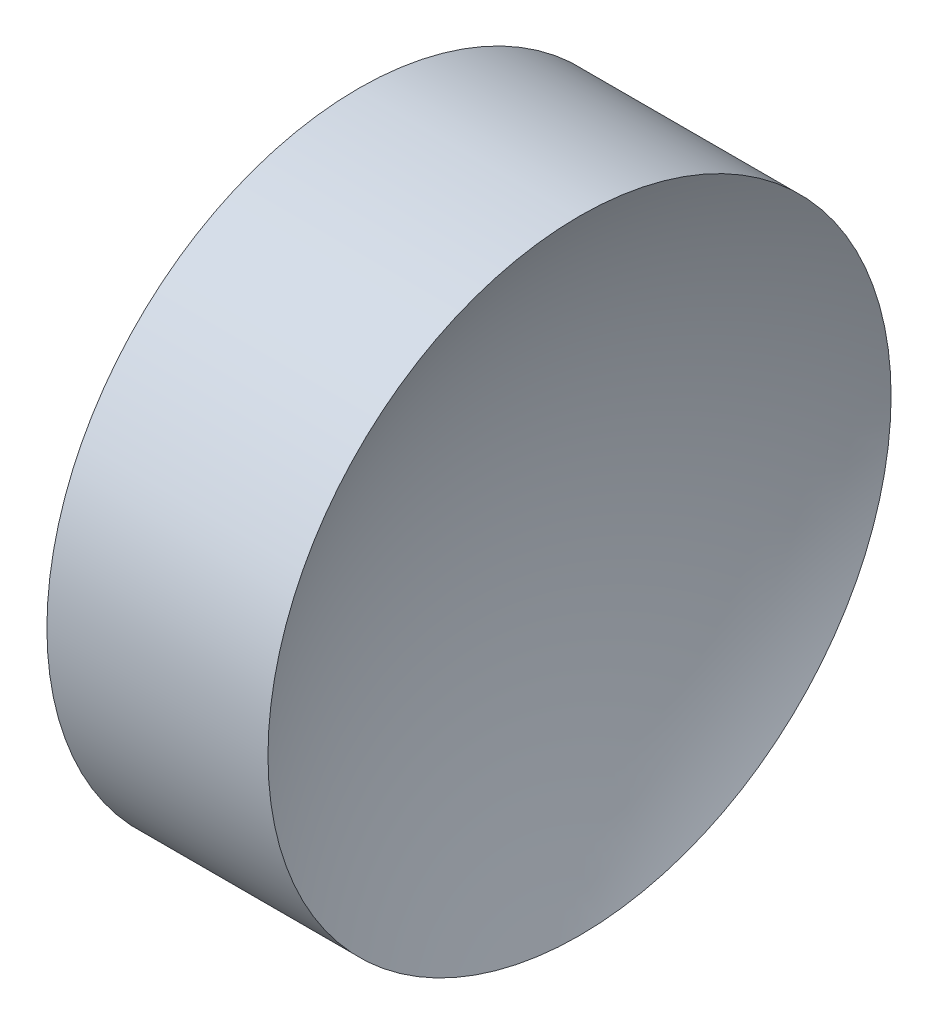
from build123d import *


with BuildPart() as part:
    # 草图1 → 旋转1 (revolve)
    with BuildSketch(Plane.XY, mode=Mode.PRIVATE) as revolve_1_sk:
        with BuildLine():
            Line((94.840443968, 52.178082298), (97.340443968, 52.178082298))
            ThreePointArc((97.340443968, 52.178082298), (98.167254795, 58.733385153), (100.595898175, 64.878082298))
            Line((100.595898175, 64.878082298), (96.090443968, 64.878082298))
            Line((96.090443968, 64.878082298), (91.584989762, 64.878082298))
            ThreePointArc((91.584989762, 64.878082298), (94.013633141, 58.733385153), (94.840443968, 52.178082298))
        make_face()
    revolve(revolve_1_sk.sketch.rotate(Axis((84.899722228, 52.178082298, 0), (1, 0, 0)), 90), axis=Axis((84.899722228, 52.178082298, 0), (1, 0, 0)))  # turned: the seam where the file's is


solid = part.part
